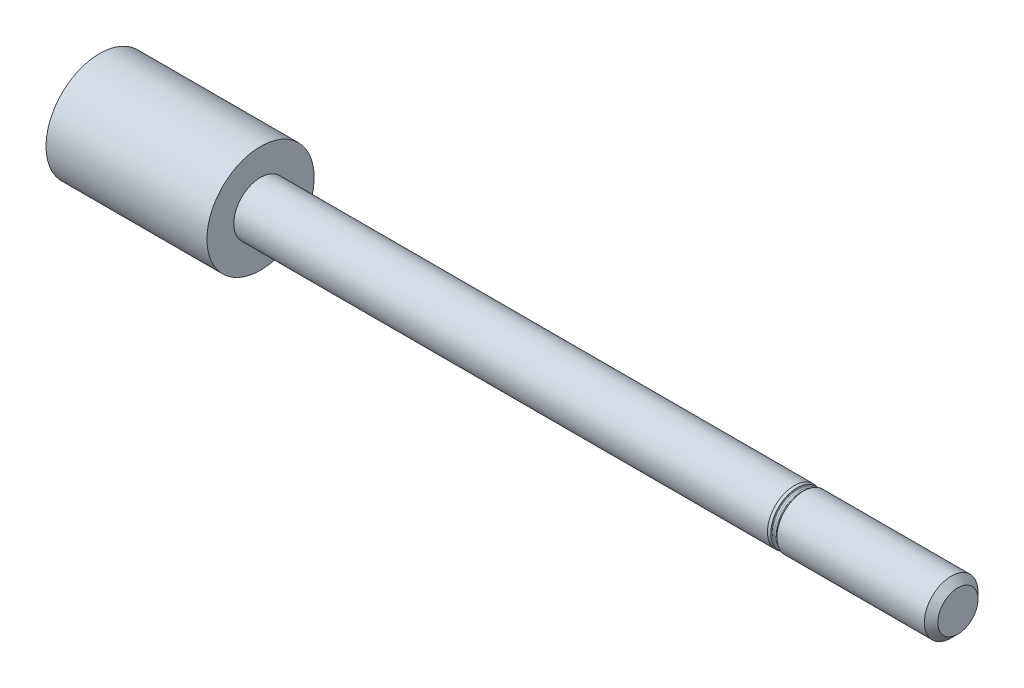
from build123d import *

# Parameters (mm, degrees)
SKETCH3_R = 4
P_L_DEPTH = 10


with BuildPart() as part:
    # Sketch1 → Revolve1 (revolve)
    with BuildSketch(Plane.XY):
        with BuildLine():
            Line((-25, 2), (14.8, 2))
            Line((14.8, 2), (15, 1.946410162))
            Line((15, 1.946410162), (15, 1.85))
            ThreePointArc((15, 1.85), (15.029289322, 1.779289322), (15.1, 1.75))
            Line((15.1, 1.75), (15.208578644, 1.75))
            ThreePointArc((15.208578644, 1.75), (15.246846987, 1.757612047), (15.279289322, 1.779289322))
            Line((15.279289322, 1.779289322), (15.5, 2))
            Line((15.5, 2), (26.5, 2))
            Line((26.5, 2), (27, 1.5))
            Line((27, 1.5), (27, 0))
            Line((27, 0), (-27, 0))
            Line((-27, 0), (-27, 4))
            Line((-27, 4), (-25, 4))
            Line((-25, 4), (-25, 2))
        make_face()
    revolve(axis=Axis((0, 0, 0), (1, 0, 0)))

    # Sketch3 → P-L (add)
    with BuildSketch(Plane.ZY.offset(27)):
        Circle(SKETCH3_R)
    extrude(amount=P_L_DEPTH)


solid = part.part
